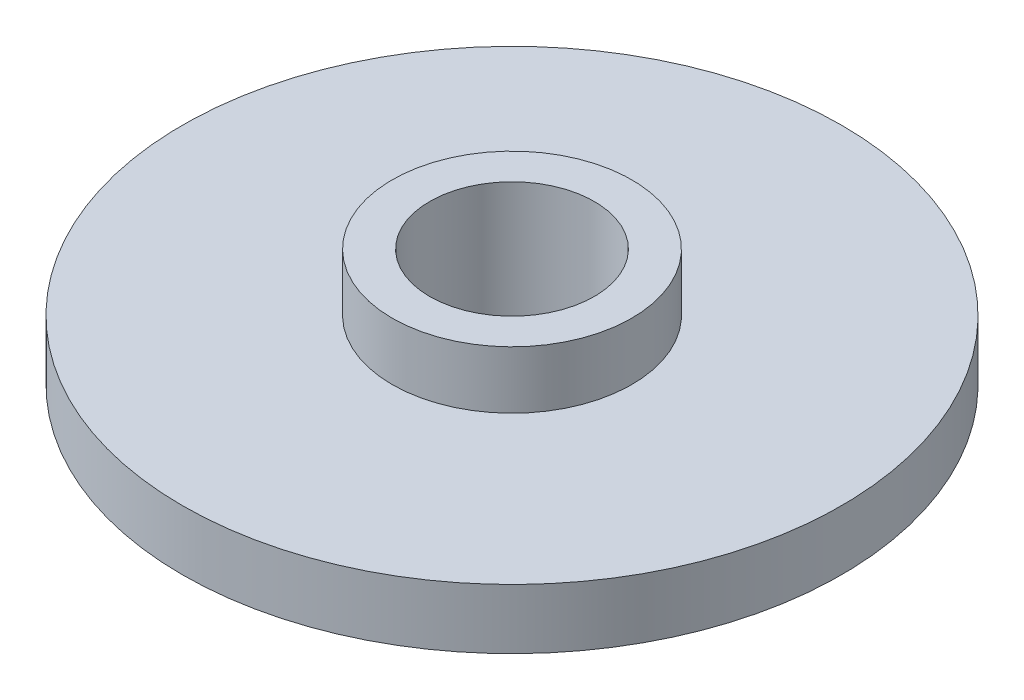
from build123d import *

# Parameters (mm, degrees)
SKETCH1_R           = 5.5
BOSS_EXTRUDE1_DEPTH = 1
SKETCH2_R           = 2
BOSS_EXTRUDE2_DEPTH = 0.96
SKETCH3_R           = 1.374255277
CUT_EXTRUDE1_DEPTH  = 6.96


with BuildPart() as part:
    # Sketch1 → Boss-Extrude1 (new body)
    with BuildSketch(Plane(origin=(0, 0, 0), x_dir=(1, 0, 0), z_dir=(0, 1, 0))):
        Circle(SKETCH1_R)
    extrude(amount=BOSS_EXTRUDE1_DEPTH)

    # Sketch2 → Boss-Extrude2 (add)
    with BuildSketch(Plane(origin=(0, 1, 0), x_dir=(1, 0, 0), z_dir=(0, 1, 0))):
        Circle(SKETCH2_R)
    extrude(amount=BOSS_EXTRUDE2_DEPTH)

    # Sketch3 → Cut-Extrude1 (cut)
    with BuildSketch(Plane(origin=(0, 1.96, 0), x_dir=(1, 0, 0), z_dir=(0, 1, 0))):
        Circle(SKETCH3_R)
    extrude(amount=-CUT_EXTRUDE1_DEPTH, mode=Mode.SUBTRACT)


solid = part.part
